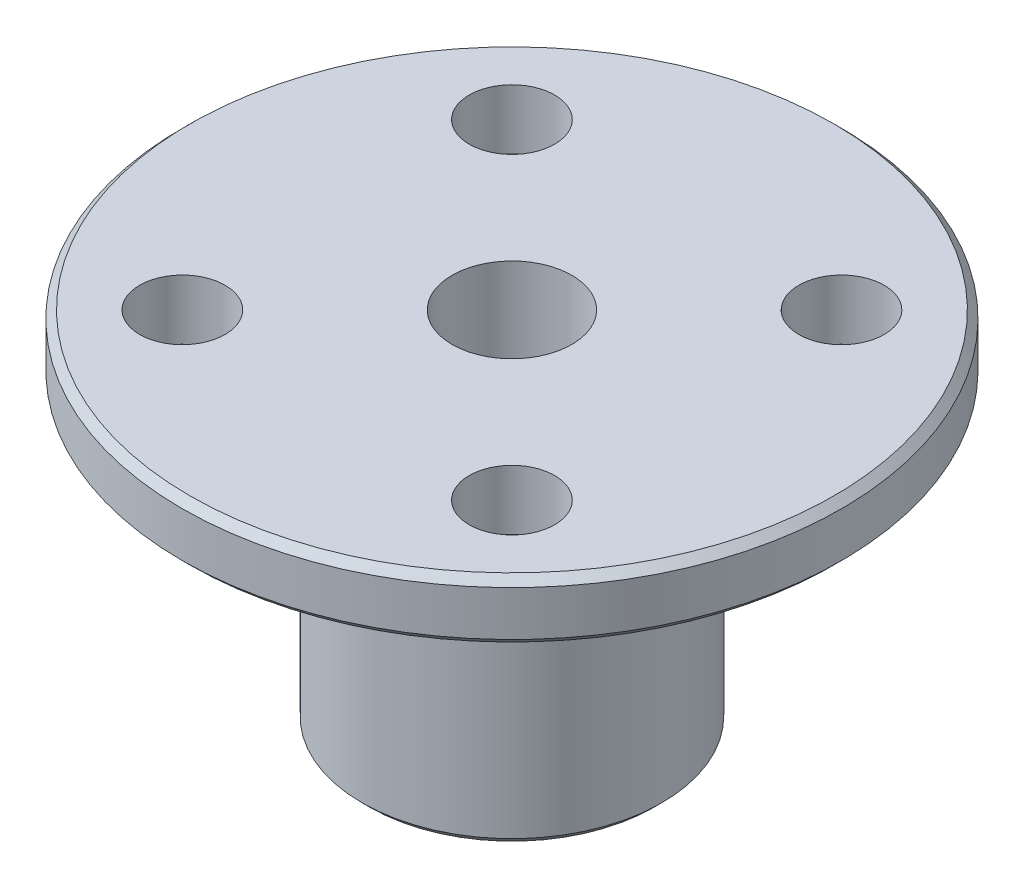
from build123d import *

# Parameters (mm, degrees)
SKETCH1_R           = 11
SKETCH1_R_2         = 2
SKETCH1_R_3         = 1.425
BOSS_EXTRUDE1_DEPTH = 2
SKETCH1_3_R         = 5
SKETCH1_3_R_2       = 2
BOSS_EXTRUDE2_DEPTH = 12
CHAMFER1_SIZE       = 0.25


with BuildPart() as part:
    # Sketch1 → Boss-Extrude1 (new body)
    with BuildSketch(Plane(origin=(0, 0, 0), x_dir=(1, 0, 0), z_dir=(0, 1, 0))):
        Circle(SKETCH1_R)
        Circle(SKETCH1_R_2, mode=Mode.SUBTRACT)
        with Locations((-5.5, 5.5)):
            Circle(SKETCH1_R_3, mode=Mode.SUBTRACT)
        with Locations((5.5, 5.5)):
            Circle(SKETCH1_R_3, mode=Mode.SUBTRACT)
        with Locations((5.5, -5.5)):
            Circle(SKETCH1_R_3, mode=Mode.SUBTRACT)
        with Locations((-5.5, -5.5)):
            Circle(SKETCH1_R_3, mode=Mode.SUBTRACT)
    extrude(amount=-BOSS_EXTRUDE1_DEPTH)

    # Sketch1_3 → Boss-Extrude2 (add)
    with BuildSketch(Plane(origin=(0, 0, 0), x_dir=(1, 0, 0), z_dir=(0, 1, 0))):
        Circle(SKETCH1_3_R)
        Circle(SKETCH1_3_R_2, mode=Mode.SUBTRACT)
    extrude(amount=-BOSS_EXTRUDE2_DEPTH)

    # Chamfer1
    chamfer1_edges = [part.edges().sort_by_distance(p)[0] for p in [
        (-5, -12, 0),
        (-5, -2, 0),
        (-2, -12, 0),
        (-11, -2, 0),
        (-11, 0, 0),
    ]]
    chamfer(chamfer1_edges, length=CHAMFER1_SIZE)


solid = part.part
